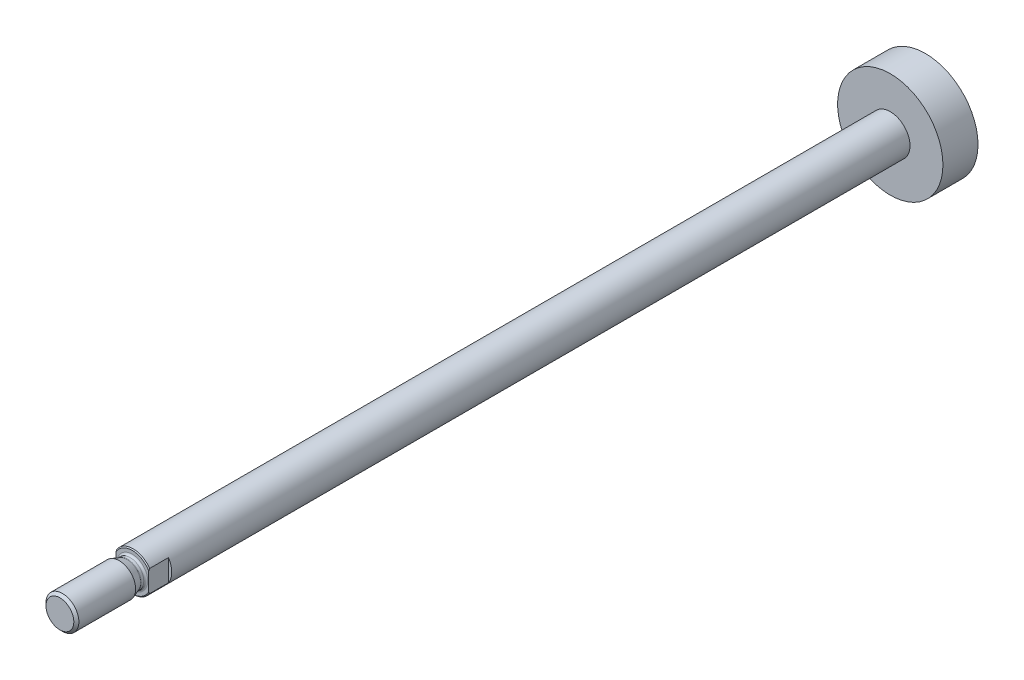
from build123d import *

# Parameters (mm, degrees)
CUT_EXTRUDE1_DEPTH      = 10
CUT_EXTRUDE1_DEPTH_BACK = 10


with BuildPart() as part:
    # Sketch1 → Revolve1 (revolve)
    with BuildSketch(Plane(origin=(0, 0, 0), x_dir=(0, 0, -1), z_dir=(1, 0, 0))):
        Polygon((-25.1, 0), (-25.1, 5.717157288), (-24.817157288, 6), (205.333333333, 6), (205.333333333, 16), (216, 16), (216, 0), align=None)
    revolve(axis=Axis((0, 0, -216), (0, 0, 1)))

    # Sketch2 → Cut-Extrude1 (cut, two sides: drawn at the far end of the back side and taken through both)
    with BuildSketch(Plane(origin=(0, 0, 0), x_dir=(1, 0, 0), z_dir=(0, 1, 0)).offset(-CUT_EXTRUDE1_DEPTH_BACK)):
        Polygon((-10, -39.1), (10, -39.1), (10, -19.1), (5, -19.1), (5, -31.1), (-5, -31.1), (-5, -19.1), (-10, -19.1), align=None)
    extrude(amount=CUT_EXTRUDE1_DEPTH + CUT_EXTRUDE1_DEPTH_BACK, mode=Mode.SUBTRACT)

    # Sketch3 → Revolve2 (revolve)
    with BuildSketch(Plane(origin=(0, 0, 0), x_dir=(0, 0, -1), z_dir=(1, 0, 0))):
        with BuildLine():
            Line((-47.1, 0), (-47.1, 4.233))
            Line((-47.1, 4.233), (-46.333, 5))
            Line((-46.333, 5), (-29.072729678, 5))
            Line((-29.072729678, 5), (-26.699415898, 4.136184428))
            ThreePointArc((-26.699415898, 4.136184428), (-26.598392718, 4.109115348), (-26.494203812, 4.1))
            Line((-26.494203812, 4.1), (-25.7, 4.1))
            ThreePointArc((-25.7, 4.1), (-25.275735931, 4.275735931), (-25.1, 4.7))
            Line((-25.1, 4.7), (-24.5, 4.7))
            Line((-24.5, 4.7), (-24.5, 0))
            Line((-24.5, 0), (-47.1, 0))
        make_face()
    revolve(axis=Axis((0, 0, 24.5), (0, 0, 1)))


solid = part.part
